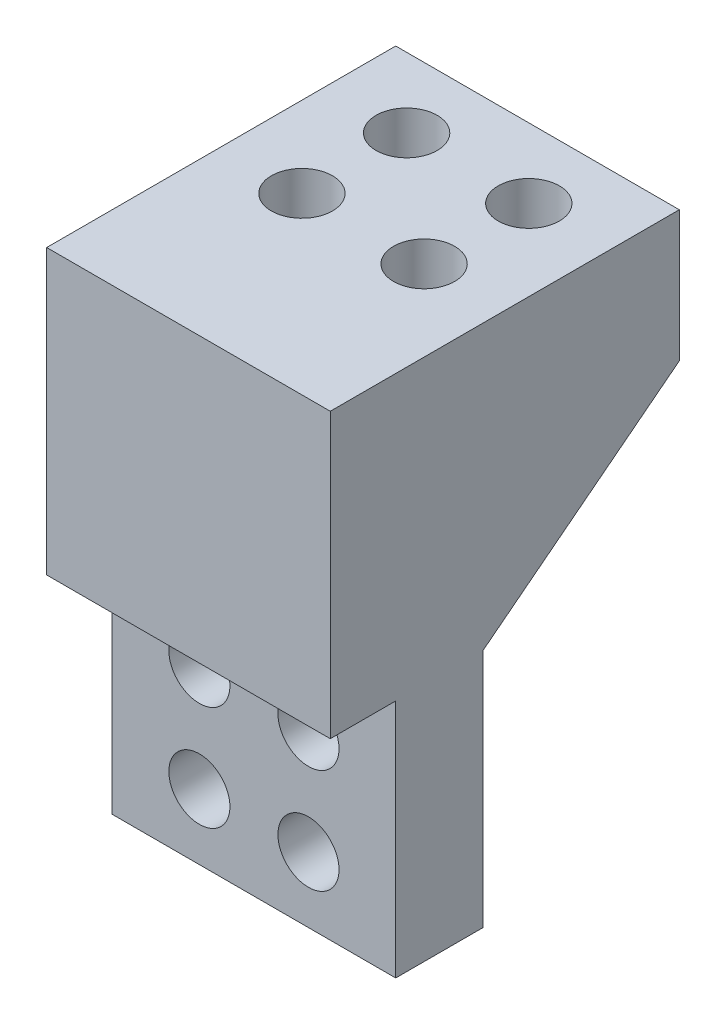
from build123d import *

# Parameters (mm, degrees)
CROQUIS1_W              = 65
CROQUIS1_H              = 120
SALIENTE_EXTRUIR1_DEPTH = 80
CROQUIS2_W              = 15
CROQUIS2_H              = 55
CORTAR_EXTRUIR1_DEPTH   = 80
CROQUIS3_R              = 7
CORTAR_EXTRUIR2_DEPTH   = 20
CROQUIS4_R              = 7
CORTAR_EXTRUIR3_DEPTH   = 10


with BuildPart() as part:
    # Croquis1 → Saliente-Extruir1 (new body)
    with BuildSketch(Plane.XY):
        Rectangle(CROQUIS1_W, CROQUIS1_H)
    extrude(amount=SALIENTE_EXTRUIR1_DEPTH)

    # Croquis2 → Cortar-Extruir1 (cut)
    with BuildSketch(Plane(origin=(32.5, 0, 0), x_dir=(0, 0, -1), z_dir=(1, 0, 0))):
        with Locations((-72.5, -32.5)):
            Rectangle(CROQUIS2_W, CROQUIS2_H)
        Polygon((-45, -60), (-45, -5), (0, 30), (0, -60), align=None)
    extrude(amount=-CORTAR_EXTRUIR1_DEPTH, mode=Mode.SUBTRACT)

    # Croquis3 → Cortar-Extruir2 (cut)
    with BuildSketch(Plane.XY.offset(65)):
        with Locations((-12.5, -21)):
            Circle(CROQUIS3_R)
        with Locations((-12.5, -45)):
            Circle(CROQUIS3_R)
        with Locations((12.5, -21)):
            Circle(CROQUIS3_R)
        with Locations((12.5, -45)):
            Circle(CROQUIS3_R)
    extrude(amount=-CORTAR_EXTRUIR2_DEPTH, mode=Mode.SUBTRACT)

    # Croquis4 → Cortar-Extruir3 (cut)
    with BuildSketch(Plane(origin=(0, 60, 0), x_dir=(1, 0, 0), z_dir=(0, 1, 0))):
        with Locations((14, -16)):
            Circle(CROQUIS4_R)
        with Locations((-14, -16)):
            Circle(CROQUIS4_R)
        with Locations((14, -40)):
            Circle(CROQUIS4_R)
        with Locations((-14, -40)):
            Circle(CROQUIS4_R)
    extrude(amount=-CORTAR_EXTRUIR3_DEPTH, mode=Mode.SUBTRACT)


solid = part.part
